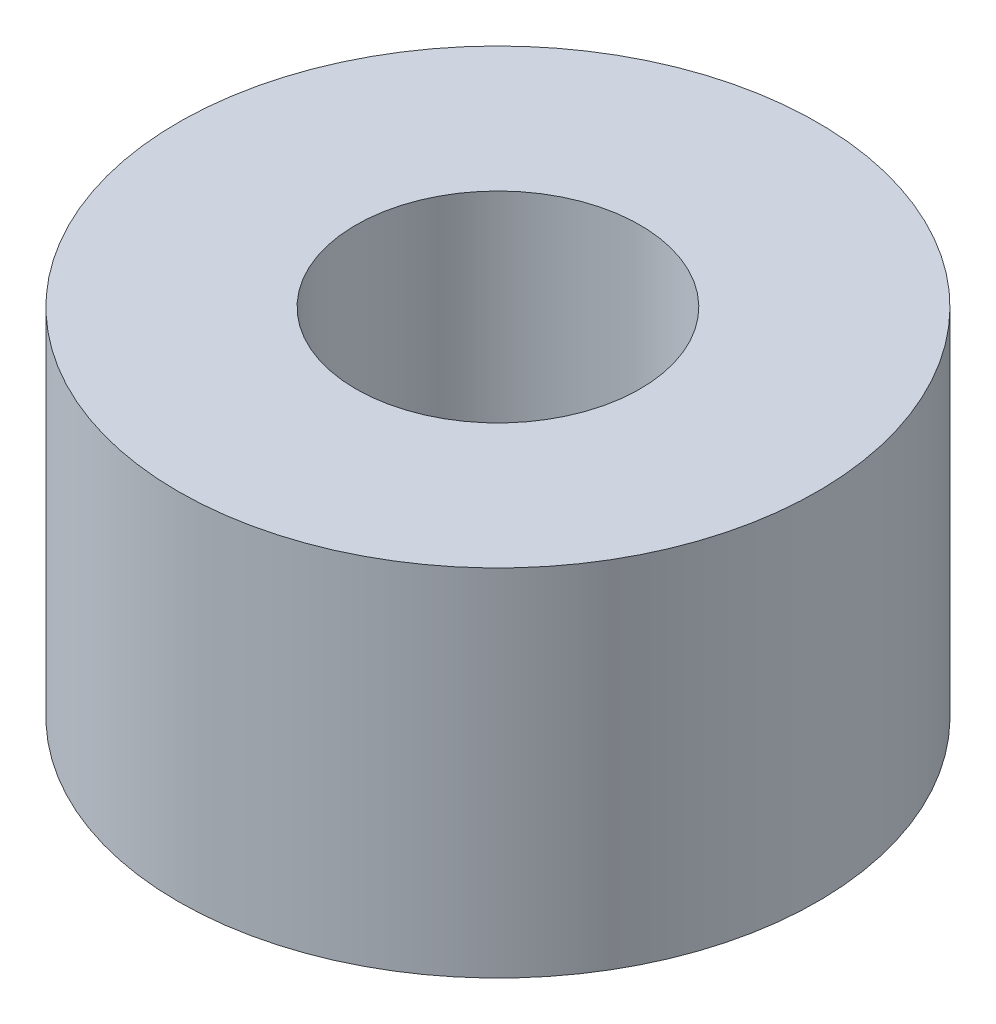
from build123d import *

# Parameters (mm, degrees)
SKETCH1_R           = 2.25
SKETCH1_R_2         = 1
BOSS_EXTRUDE1_DEPTH = 2.5


with BuildPart() as part:
    # Sketch1 → Boss-Extrude1 (new body)
    with BuildSketch(Plane(origin=(0, 0, 0), x_dir=(1, 0, 0), z_dir=(0, 1, 0))):
        Circle(SKETCH1_R)
        Circle(SKETCH1_R_2, mode=Mode.SUBTRACT)
    extrude(amount=BOSS_EXTRUDE1_DEPTH)


solid = part.part
